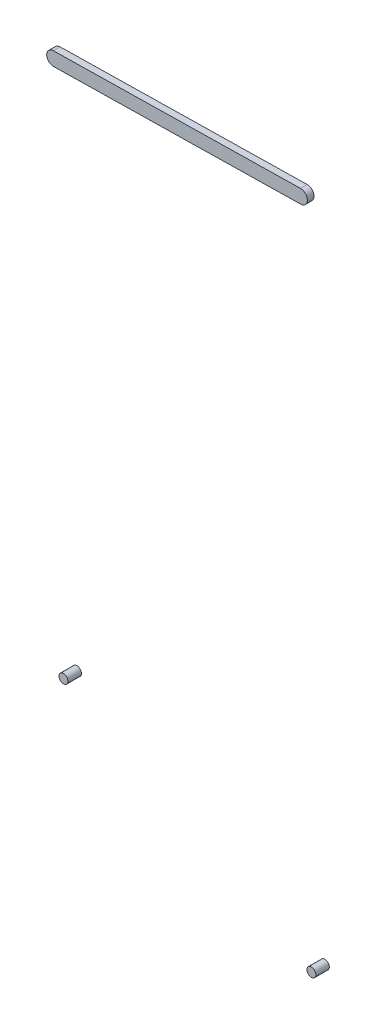
from build123d import *

# Parameters (mm, degrees)
BOSS_EXTRUDE1_DEPTH   = 1.5
SKETCH2_R             = 1
BOSS_EXTRUDE2_DEPTH   = 3
BOSS_EXTRUDE2_2_DEPTH = 3


with BuildPart() as part:
    # Sketch1 → Boss-Extrude1 (new body)
    with BuildSketch(Plane.XY):
        with BuildLine():
            Line((-55.066213656, 15.540423387), (-0.026647042, 16.511040453))
            ThreePointArc((-0.026647042, 16.511040453), (1.511040453, 15.026647042), (0.026647042, 13.488959547))
            Line((0.026647042, 13.488959547), (-55.012919571, 12.518342481))
            ThreePointArc((-55.012919571, 12.518342481), (-56.550607067, 14.002735892), (-55.066213656, 15.540423387))
        make_face()
    extrude(amount=BOSS_EXTRUDE1_DEPTH)


with BuildPart() as body_2:
    # Sketch2 → Boss-Extrude2 (new body)
    with BuildSketch(Plane(origin=(0, 0, 0), x_dir=(-1, 0, 0), z_dir=(0, 0, -1))):
        with Locations((54.313883932, -105.968422815)):
            Circle(SKETCH2_R)
    extrude(amount=BOSS_EXTRUDE2_DEPTH)


with BuildPart() as body_3:
    # Sketch2 → Boss-Extrude2 2 (new body)
    with BuildSketch(Plane(origin=(0, 0, 0), x_dir=(-1, 0, 0), z_dir=(0, 0, -1))):
        with Locations((-0.907103352, -134.997257187)):
            Circle(SKETCH2_R)
    extrude(amount=BOSS_EXTRUDE2_2_DEPTH)


solid = Compound([part.part, body_2.part, body_3.part])
